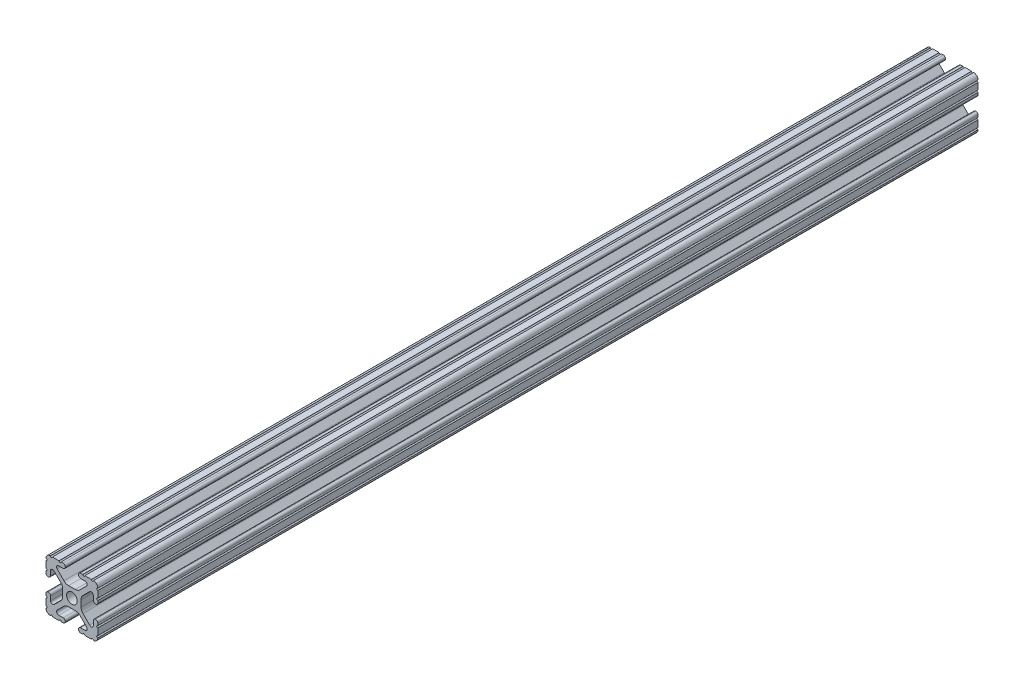
from build123d import *

# Parameters (mm, degrees)
SKETCH1_R           = 2.6035
BOSS_EXTRUDE1_DEPTH = 215.9


with BuildPart() as part:
    # Sketch1 → Boss-Extrude1 (new body, symmetric)
    with BuildSketch(Plane.XY):
        with BuildLine():
            Line((-7.179650497, -8.645192506), (-3.952270251, -5.423690499))
            ThreePointArc((-3.952270251, -5.423690499), (-2.922936451, -4.736929036), (-1.709253557, -4.4958))
            Line((-1.709253557, -4.4958), (1.709253557, -4.4958))
            ThreePointArc((1.709253557, -4.4958), (2.922936451, -4.736929036), (3.952270251, -5.423690499))
            Line((3.952270251, -5.423690499), (7.179650497, -8.645192506))
            ThreePointArc((7.179650497, -8.645192506), (7.41473083, -9.822813117), (6.416408329, -10.4902))
            Line((6.416408329, -10.4902), (4.287512407, -10.4902))
            ThreePointArc((4.287512407, -10.4902), (3.54574862, -10.79744862), (3.2385, -11.539212407))
            Line((3.2385, -11.539212407), (3.2385, -11.650987593))
            ThreePointArc((3.2385, -11.650987593), (3.54574862, -12.39275138), (4.287512407, -12.7))
            Line((4.287512407, -12.7), (5.317126718, -12.7))
            ThreePointArc((5.317126718, -12.7), (5.825126718, -12.192), (6.333126718, -12.7))
            Line((6.333126718, -12.7), (9.550443118, -12.7))
            ThreePointArc((9.550443118, -12.7), (10.058366869, -12.192000006), (10.566443095, -12.699847501))
            ThreePointArc((10.566443095, -12.699847501), (12.082537762, -12.08250727), (12.699846982, -10.566399977))
            ThreePointArc((12.699846982, -10.566399977), (12.192000006, -10.058323491), (12.7, -9.5504))
            Line((12.7, -9.5504), (12.7, -6.3330836))
            ThreePointArc((12.7, -6.3330836), (12.192, -5.8250836), (12.7, -5.3170836))
            Line((12.7, -5.3170836), (12.7, -4.287469289))
            ThreePointArc((12.7, -4.287469289), (12.39275138, -3.545705502), (11.650987593, -3.238456882))
            Line((11.650987593, -3.238456882), (11.539212407, -3.238456882))
            ThreePointArc((11.539212407, -3.238456882), (10.79744862, -3.545705502), (10.4902, -4.287469289))
            Line((10.4902, -4.287469289), (10.4902, -6.402089023))
            ThreePointArc((10.4902, -6.402089023), (9.856505071, -7.351067942), (8.737131347, -7.129408934))
            Line((8.737131347, -7.129408934), (5.441005833, -3.840816462))
            ThreePointArc((5.441005833, -3.840816462), (4.750877967, -2.809883091), (4.5085, -1.593185507))
            Line((4.5085, -1.593185507), (4.5085, 1.593185507))
            ThreePointArc((4.5085, 1.593185507), (4.750877967, 2.809883091), (5.441005833, 3.840816462))
            Line((5.441005833, 3.840816462), (8.737131347, 7.129408934))
            ThreePointArc((8.737131347, 7.129408934), (9.856505071, 7.351067942), (10.4902, 6.402089023))
            Line((10.4902, 6.402089023), (10.4902, 4.287469289))
            ThreePointArc((10.4902, 4.287469289), (10.79744862, 3.545705502), (11.539212407, 3.238456882))
            Line((11.539212407, 3.238456882), (11.650987593, 3.238456882))
            ThreePointArc((11.650987593, 3.238456882), (12.39275138, 3.545705502), (12.7, 4.287469289))
            Line((12.7, 4.287469289), (12.7, 5.3170836))
            ThreePointArc((12.7, 5.3170836), (12.192, 5.8250836), (12.7, 6.3330836))
            Line((12.7, 6.3330836), (12.7, 9.5504))
            ThreePointArc((12.7, 9.5504), (12.192000006, 10.058323491), (12.699846982, 10.566399977))
            ThreePointArc((12.699846982, 10.566399977), (12.082537762, 12.08250727), (10.566443095, 12.699847501))
            ThreePointArc((10.566443095, 12.699847501), (10.058366869, 12.192000006), (9.550443118, 12.7))
            Line((9.550443118, 12.7), (6.333126718, 12.7))
            ThreePointArc((6.333126718, 12.7), (5.825126718, 12.192), (5.317126718, 12.7))
            Line((5.317126718, 12.7), (4.287512407, 12.7))
            ThreePointArc((4.287512407, 12.7), (3.54574862, 12.39275138), (3.2385, 11.650987593))
            Line((3.2385, 11.650987593), (3.2385, 11.539212407))
            ThreePointArc((3.2385, 11.539212407), (3.54574862, 10.79744862), (4.287512407, 10.4902))
            Line((4.287512407, 10.4902), (6.476788598, 10.4902))
            ThreePointArc((6.476788598, 10.4902), (7.432222385, 9.85140422), (7.207036008, 8.724370562))
            Line((7.207036008, 8.724370562), (3.898272566, 5.423169045))
            ThreePointArc((3.898272566, 5.423169045), (2.869120213, 4.736787962), (1.655778399, 4.4958))
            Line((1.655778399, 4.4958), (-1.655778399, 4.4958))
            ThreePointArc((-1.655778399, 4.4958), (-2.869120213, 4.736787962), (-3.898272566, 5.423169045))
            Line((-3.898272566, 5.423169045), (-7.207036008, 8.724370562))
            ThreePointArc((-7.207036008, 8.724370562), (-7.432222385, 9.85140422), (-6.476788598, 10.4902))
            Line((-6.476788598, 10.4902), (-4.287512407, 10.4902))
            ThreePointArc((-4.287512407, 10.4902), (-3.54574862, 10.79744862), (-3.2385, 11.539212407))
            Line((-3.2385, 11.539212407), (-3.2385, 11.650987593))
            ThreePointArc((-3.2385, 11.650987593), (-3.54574862, 12.39275138), (-4.287512407, 12.7))
            Line((-4.287512407, 12.7), (-5.317126718, 12.7))
            ThreePointArc((-5.317126718, 12.7), (-5.825126718, 12.192), (-6.333126718, 12.7))
            Line((-6.333126718, 12.7), (-9.550443118, 12.7))
            ThreePointArc((-9.550443118, 12.7), (-10.058366869, 12.192000006), (-10.566443095, 12.699847501))
            ThreePointArc((-10.566443095, 12.699847501), (-12.082537762, 12.08250727), (-12.699846982, 10.566399977))
            ThreePointArc((-12.699846982, 10.566399977), (-12.192000006, 10.058323491), (-12.7, 9.5504))
            Line((-12.7, 9.5504), (-12.7, 6.3330836))
            ThreePointArc((-12.7, 6.3330836), (-12.192, 5.8250836), (-12.7, 5.3170836))
            Line((-12.7, 5.3170836), (-12.7, 4.287469289))
            ThreePointArc((-12.7, 4.287469289), (-12.39275138, 3.545705502), (-11.650987593, 3.238456882))
            Line((-11.650987593, 3.238456882), (-11.539212407, 3.238456882))
            ThreePointArc((-11.539212407, 3.238456882), (-10.79744862, 3.545705502), (-10.4902, 4.287469289))
            Line((-10.4902, 4.287469289), (-10.4902, 6.402089023))
            ThreePointArc((-10.4902, 6.402089023), (-9.856505071, 7.351067942), (-8.737131347, 7.129408934))
            Line((-8.737131347, 7.129408934), (-5.441005833, 3.840816462))
            ThreePointArc((-5.441005833, 3.840816462), (-4.750877967, 2.809883091), (-4.5085, 1.593185507))
            Line((-4.5085, 1.593185507), (-4.5085, -1.593185507))
            ThreePointArc((-4.5085, -1.593185507), (-4.750877967, -2.809883091), (-5.441005833, -3.840816462))
            Line((-5.441005833, -3.840816462), (-8.737131347, -7.129408934))
            ThreePointArc((-8.737131347, -7.129408934), (-9.856505071, -7.351067942), (-10.4902, -6.402089023))
            Line((-10.4902, -6.402089023), (-10.4902, -4.287469289))
            ThreePointArc((-10.4902, -4.287469289), (-10.79744862, -3.545705502), (-11.539212407, -3.238456882))
            Line((-11.539212407, -3.238456882), (-11.650987593, -3.238456882))
            ThreePointArc((-11.650987593, -3.238456882), (-12.39275138, -3.545705502), (-12.7, -4.287469289))
            Line((-12.7, -4.287469289), (-12.7, -5.3170836))
            ThreePointArc((-12.7, -5.3170836), (-12.192, -5.8250836), (-12.7, -6.3330836))
            Line((-12.7, -6.3330836), (-12.7, -9.5504))
            ThreePointArc((-12.7, -9.5504), (-12.192000006, -10.058323491), (-12.699846982, -10.566399977))
            ThreePointArc((-12.699846982, -10.566399977), (-12.082537762, -12.08250727), (-10.566443095, -12.699847501))
            ThreePointArc((-10.566443095, -12.699847501), (-10.058366869, -12.192000006), (-9.550443118, -12.7))
            Line((-9.550443118, -12.7), (-6.333126718, -12.7))
            ThreePointArc((-6.333126718, -12.7), (-5.825126718, -12.192), (-5.317126718, -12.7))
            Line((-5.317126718, -12.7), (-4.287512407, -12.7))
            ThreePointArc((-4.287512407, -12.7), (-3.54574862, -12.39275138), (-3.2385, -11.650987593))
            Line((-3.2385, -11.650987593), (-3.2385, -11.539212407))
            ThreePointArc((-3.2385, -11.539212407), (-3.54574862, -10.79744862), (-4.287512407, -10.4902))
            Line((-4.287512407, -10.4902), (-6.416408329, -10.4902))
            ThreePointArc((-6.416408329, -10.4902), (-7.41473083, -9.822813117), (-7.179650497, -8.645192506))
        make_face()
        Circle(SKETCH1_R, mode=Mode.SUBTRACT)
    extrude(amount=BOSS_EXTRUDE1_DEPTH, both=True)


solid = part.part
